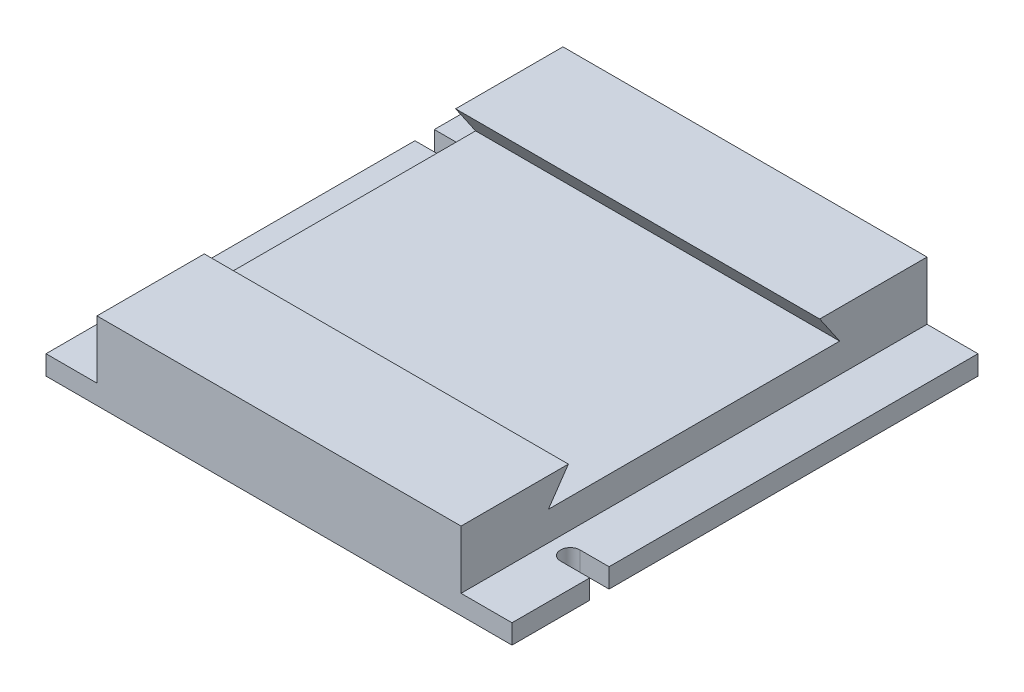
from build123d import *

# Parameters (mm, degrees)
EXTRUDE_1_DEPTH     = 240
CUT_EXTRUDE_1_DEPTH = 41
SKETCH_3_W          = 26.245299516
SKETCH_3_H          = 240
CUT_EXTRUDE_2_DEPTH = 30


with BuildPart() as part:
    # Эскиз1 → Бобышка-Вытянуть1 (new body)
    with BuildSketch(Plane(origin=(0, 0, 0), x_dir=(0, 0, -1), z_dir=(1, 0, 0))):
        Polygon((-120, 0), (120, 0), (120, 40), (64.71995712, 40), (75, 25), (-75, 25), (-64.71995712, 40), (-120, 40), align=None)
    extrude(amount=EXTRUDE_1_DEPTH)

    # Эскиз2 → Вырез-Вытянуть1 (cut, through all)
    with BuildSketch(Plane.XZ):
        with BuildLine():
            Line((240, 80), (240, 70))
            Line((240, 70), (225, 70))
            ThreePointArc((225, 70), (220, 75), (225, 80))
            Line((225, 80), (240, 80))
        make_face()
        with BuildLine():
            Line((0, -80), (0, -70))
            Line((0, -70), (15, -70))
            ThreePointArc((15, -70), (20, -75), (15, -80))
            Line((15, -80), (0, -80))
        make_face()
    extrude(amount=-CUT_EXTRUDE_1_DEPTH, mode=Mode.SUBTRACT)

    # Эскиз3 → Вырез-Вытянуть2 (cut)
    with BuildSketch(Plane(origin=(0, 40, 0), x_dir=(1, 0, 0), z_dir=(0, 1, 0))):
        with Locations((13.122649758, 0)):
            Rectangle(SKETCH_3_W, SKETCH_3_H)
        with Locations((226.877350242, 0)):
            Rectangle(SKETCH_3_W, SKETCH_3_H)
    extrude(amount=-CUT_EXTRUDE_2_DEPTH, mode=Mode.SUBTRACT)


solid = part.part
